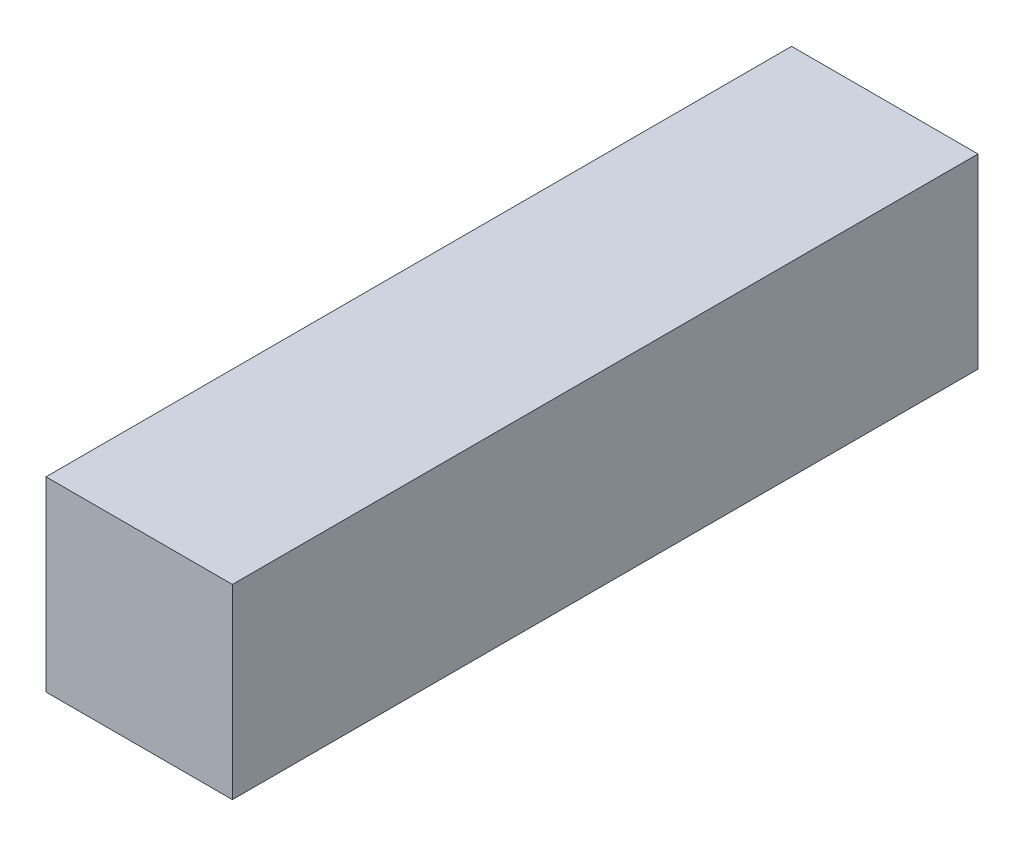
from build123d import *

# Parameters (mm, degrees)
SKETCH1_W           = 5000
SKETCH1_H           = 20000
BOSS_EXTRUDE1_DEPTH = 5000


with BuildPart() as part:
    # Sketch1 → Boss-Extrude1 (new body)
    with BuildSketch(Plane(origin=(0, 0, 0), x_dir=(1, 0, 0), z_dir=(0, 1, 0))):
        Rectangle(SKETCH1_W, SKETCH1_H)
    extrude(amount=BOSS_EXTRUDE1_DEPTH)


solid = part.part
